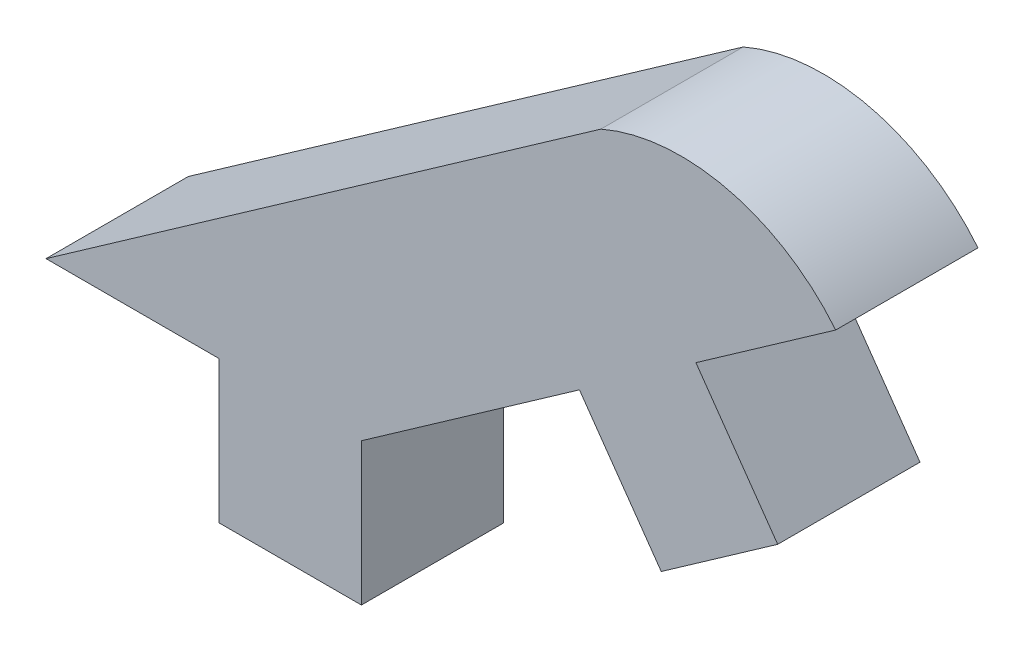
from build123d import *

# Parameters (mm, degrees)
BOSS_EXTRUDE1_DEPTH = 1.524


with BuildPart() as part:
    # Sketch1 → Boss-Extrude1 (new body)
    with BuildSketch(Plane.XY):
        with BuildLine():
            Line((26.703585716, 0), (26.703585716, -1.524))
            Line((26.703585716, -1.524), (28.227585716, -1.524))
            Line((28.227585716, -1.524), (28.227585716, 0))
            Line((28.227585716, 0), (30.562754439, 1.639658569))
            Line((30.562754439, 1.639658569), (31.438516966, 0.39241521))
            Line((31.438516966, 0.39241521), (32.685760325, 1.268177737))
            Line((32.685760325, 1.268177737), (31.809997798, 2.515421096))
            Line((31.809997798, 2.515421096), (33.306965818, 3.566529915))
            ThreePointArc((33.306965818, 3.566529915), (32.151803022, 4.293127988), (30.792442306, 4.172777296))
            Line((30.792442306, 4.172777296), (24.84965689, 0))
            Line((24.84965689, 0), (26.703585716, 0))
        make_face()
    extrude(amount=BOSS_EXTRUDE1_DEPTH)


solid = part.part
